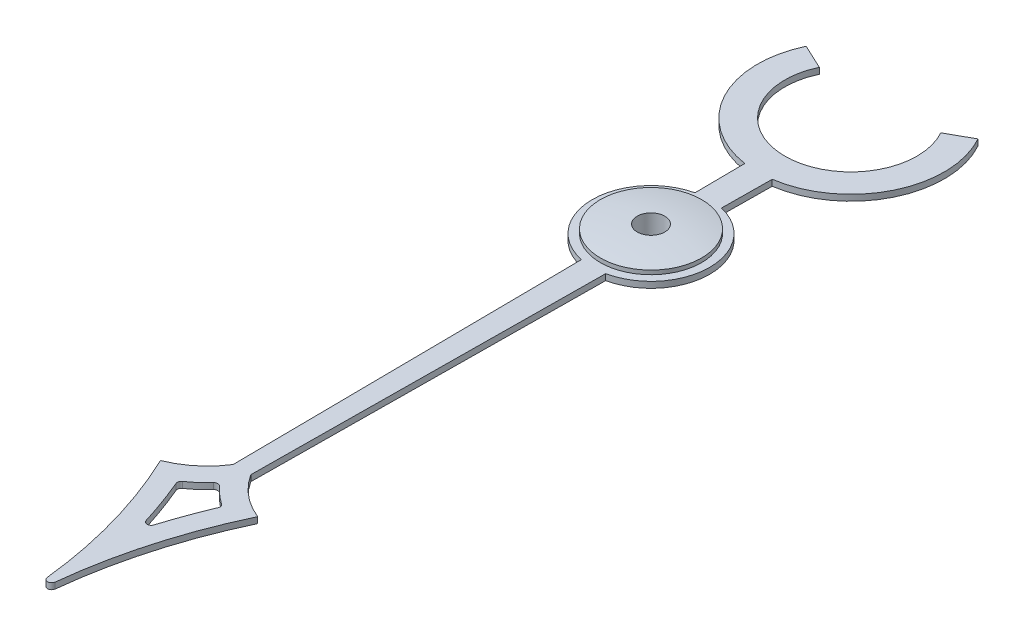
from build123d import *

# Parameters (mm, degrees)
ESQUISSE2_R        = 0.75
BOSS_EXTRU_1_DEPTH = 0.15


with BuildPart() as part:
    # Esquisse1 → Révolution1 (revolve)
    with BuildSketch(Plane.XY):
        with BuildLine():
            Line((-0.34, 0), (-0.75, 0))
            Line((-0.75, 0), (-0.75, 0.3))
            Line((-0.75, 0.3), (-1.25, 0.3))
            Line((-1.25, 0.3), (-1.25, 0.4))
            ThreePointArc((-1.25, 0.4), (-0.796811957, 0.466488811), (-0.34, 0.5))
            Line((-0.34, 0.5), (-0.34, 0))
        make_face()
    revolve(axis=Axis((0, 0, 0), (0, 1, 0)))


with BuildPart() as body_2:
    # Esquisse2 → Boss.-Extru.1 (new body)
    with BuildSketch(Plane.XZ.offset(-0.3)):
        with BuildLine():
            Line((0.326759739, -1.412702401), (0.338500561, -2.654946389))
            ThreePointArc((0.338500561, -2.654946389), (2.069645511, -3.917205167), (2.016508458, -6.059012001))
            Line((2.016508458, -6.059012001), (1.426021174, -5.730816496))
            ThreePointArc((1.426021174, -5.730816496), (0.055576886, -3.306493599), (-1.476723272, -5.631900076))
            Line((-1.476723272, -5.631900076), (-2.088187509, -5.91912649))
            ThreePointArc((-2.088187509, -5.91912649), (-2.033696556, -3.847305771), (-0.338500561, -2.654946389))
            Line((-0.338500561, -2.654946389), (-0.326759739, -1.412702401))
            ThreePointArc((-0.326759739, -1.412702401), (-1.449935242, 0.013703775), (-0.3, 1.418626096))
            Line((-0.3, 1.418626096), (-0.217926101, 10.102498878))
            ThreePointArc((-0.217926101, 10.102498878), (-0.645390878, 10.5850161), (-1.2, 10.913585311))
            ThreePointArc((-1.2, 10.913585311), (-0.484840229, 12.819677692), (-0.098277599, 14.818480083))
            ThreePointArc((-0.098277599, 14.818480083), (0, 14.9), (0.098277599, 14.818480083))
            ThreePointArc((0.098277599, 14.818480083), (0.484840229, 12.819677692), (1.2, 10.913585311))
            ThreePointArc((1.2, 10.913585311), (0.645390878, 10.5850161), (0.217926101, 10.102498878))
            Line((0.217926101, 10.102498878), (0.3, 1.418626096))
            ThreePointArc((0.3, 1.418626096), (1.449935242, 0.013703775), (0.326759739, -1.412702401))
        make_face()
        Circle(ESQUISSE2_R, mode=Mode.SUBTRACT)
        with BuildLine():
            ThreePointArc((0.484554357, 11.090791048), (0.269465751, 10.921587766), (0.073499847, 10.730563622))
            ThreePointArc((0.073499847, 10.730563622), (0, 10.698370499), (-0.073499847, 10.730563622))
            ThreePointArc((-0.073499847, 10.730563622), (-0.269465751, 10.921587766), (-0.484554357, 11.090791048))
            ThreePointArc((-0.484554357, 11.090791048), (-0.523101788, 11.144977331), (-0.51914325, 11.211357959))
            ThreePointArc((-0.51914325, 11.211357959), (-0.293104532, 11.787237938), (-0.095515749, 12.373488673))
            ThreePointArc((-0.095515749, 12.373488673), (0, 12.44387885), (0.095515749, 12.373488673))
            ThreePointArc((0.095515749, 12.373488673), (0.293104532, 11.787237938), (0.51914325, 11.211357959))
            ThreePointArc((0.51914325, 11.211357959), (0.523101788, 11.144977331), (0.484554357, 11.090791048))
        make_face(mode=Mode.SUBTRACT)
    extrude(amount=BOSS_EXTRU_1_DEPTH)


solid = Compound([part.part, body_2.part])
